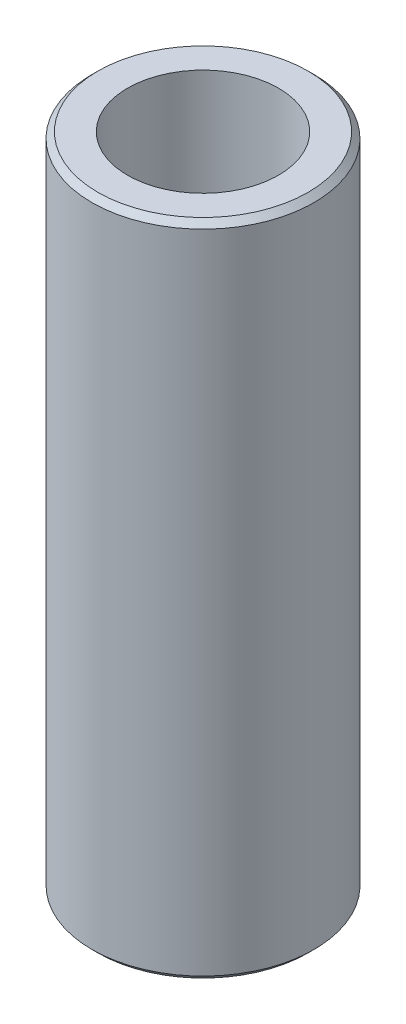
from build123d import *

# Parameters (mm, degrees)
SKETCH1_R           = 4.7625
BOSS_EXTRUDE1_DEPTH = 14.12875
CHAMFER1_SIZE       = 0.254
SKETCH2_R           = 3.2385
CUT_EXTRUDE1_DEPTH  = 29.2575


with BuildPart() as part:
    # Sketch1 → Boss-Extrude1 (new body, symmetric)
    with BuildSketch(Plane(origin=(0, 0, 0), x_dir=(1, 0, 0), z_dir=(0, 1, 0))):
        Circle(SKETCH1_R)
    extrude(amount=BOSS_EXTRUDE1_DEPTH, both=True)

    # Chamfer1
    chamfer1_edges = [part.edges().sort_by_distance(p)[0] for p in [
        (-4.7625, -14.12875, 0),
        (-4.7625, 14.12875, 0),
    ]]
    chamfer(chamfer1_edges, length=CHAMFER1_SIZE)

    # Sketch2 → Cut-Extrude1 (cut, through all)
    with BuildSketch(Plane.XZ.offset(14.12875)):
        Circle(SKETCH2_R)
    extrude(amount=-CUT_EXTRUDE1_DEPTH, mode=Mode.SUBTRACT)


solid = part.part
